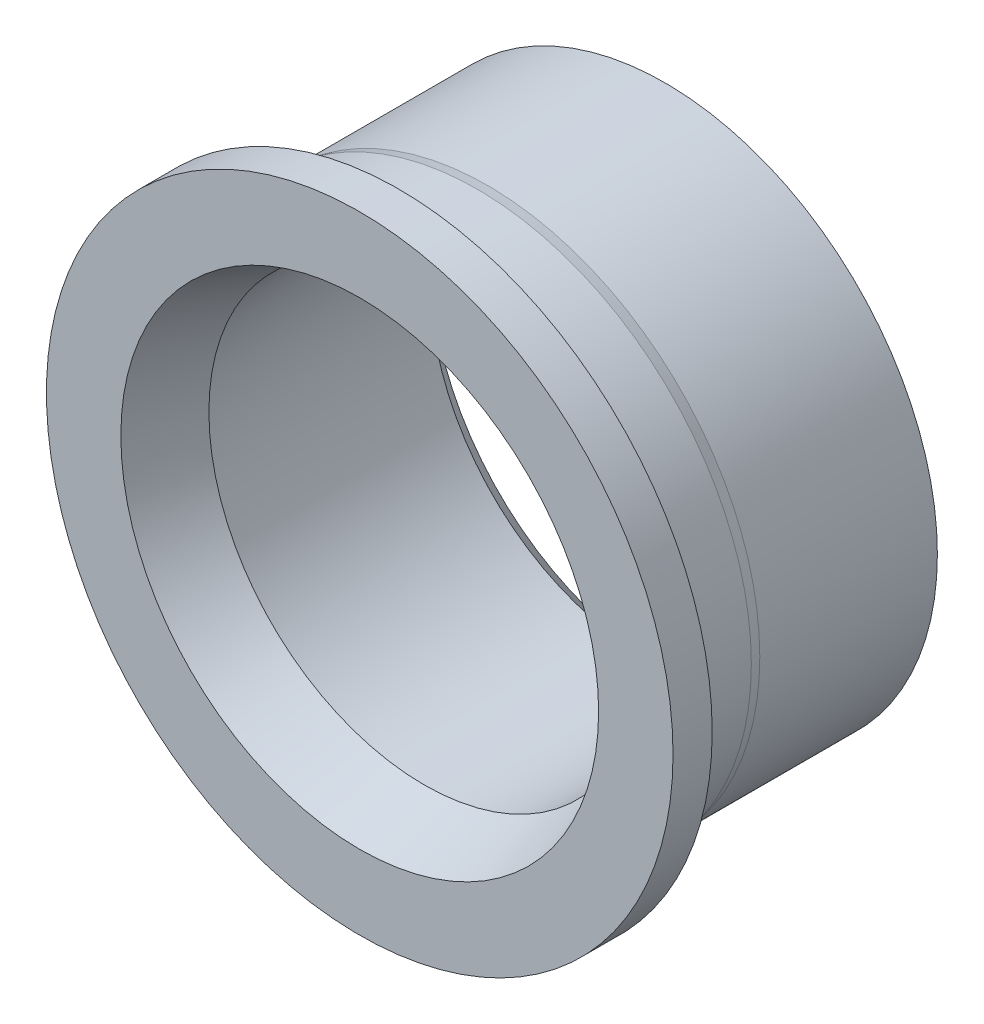
from build123d import *

# Parameters (mm, degrees)
CHAMFER_1_SIZE  = 0.5
CHAMFER_2_SIZE  = 0.6
CHAMFER_2_SIZE2 = 1.648486452


with BuildPart() as part:
    # Эскиз1 → Повернуть1 (revolve)
    with BuildSketch(Plane(origin=(0, 0, 0), x_dir=(0, 0, -1), z_dir=(1, 0, 0))):
        Polygon((0, 5.5), (7.8, 5.5), (7.8, 6.95), (3.265574507, 6.95), (3, 7), (1, 7), (1, 8), (0, 8), align=None)
    revolve(axis=Axis((0, 0, 0), (0, 0, -1)))

    # Фаска1
    chamfer_1_edges = [part.edges().sort_by_distance(p)[0] for p in [
        (0, -5.5, -7.8),
    ]]
    chamfer(chamfer_1_edges, length=CHAMFER_1_SIZE)

    # Фаска2
    chamfer_2_edges = [part.edges().sort_by_distance(p)[0] for p in [
        (0, -5.5, 0),
    ]]
    chamfer_2_side = [part.faces().sort_by_distance(p)[0] for p in [
        (0, -7.77372583, 0),
    ]]
    chamfer(chamfer_2_edges, length=CHAMFER_2_SIZE, length2=CHAMFER_2_SIZE2, reference=chamfer_2_side[0])


solid = part.part
